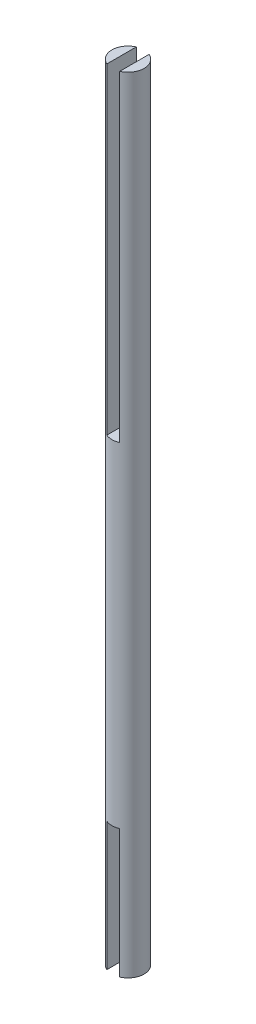
from build123d import *

# Parameters (mm, degrees)
SKETCH1_R           = 5
BOSS_EXTRUDE1_DEPTH = 104
BOSS_EXTRUDE2_DEPTH = 100
BOSS_EXTRUDE3_START = -104
BOSS_EXTRUDE3_DEPTH = 40


with BuildPart() as part:
    # Sketch1 → Boss-Extrude1 (new body)
    with BuildSketch(Plane(origin=(0, 0, 0), x_dir=(1, 0, 0), z_dir=(0, 1, 0))):
        Circle(SKETCH1_R)
    extrude(amount=BOSS_EXTRUDE1_DEPTH)

    # Sketch2 → Boss-Extrude2 (add)
    with BuildSketch(Plane(origin=(0, 104, 0), x_dir=(1, 0, 0), z_dir=(0, 1, 0))):
        with BuildLine():
            Line((-2, 4.582576), (-2, -4.582576))
            ThreePointArc((-2, -4.582576), (-5, 0), (-2, 4.582576))
        make_face()
        with BuildLine():
            Line((2, 4.582576), (2, -4.582576))
            ThreePointArc((2, -4.582576), (5, 0), (2, 4.582576))
        make_face()
    extrude(amount=BOSS_EXTRUDE2_DEPTH)

    # Sketch2_2 → Boss-Extrude3 (add)
    with BuildSketch(Plane(origin=(0, 104, 0), x_dir=(1, 0, 0), z_dir=(0, 1, 0)).offset(BOSS_EXTRUDE3_START)):
        with BuildLine():
            Line((-2, 4.582576), (-2, -4.582576))
            ThreePointArc((-2, -4.582576), (-5, 0), (-2, 4.582576))
        make_face()
        with BuildLine():
            Line((2, 4.582576), (2, -4.582576))
            ThreePointArc((2, -4.582576), (5, 0), (2, 4.582576))
        make_face()
    extrude(amount=-BOSS_EXTRUDE3_DEPTH)


solid = part.part
